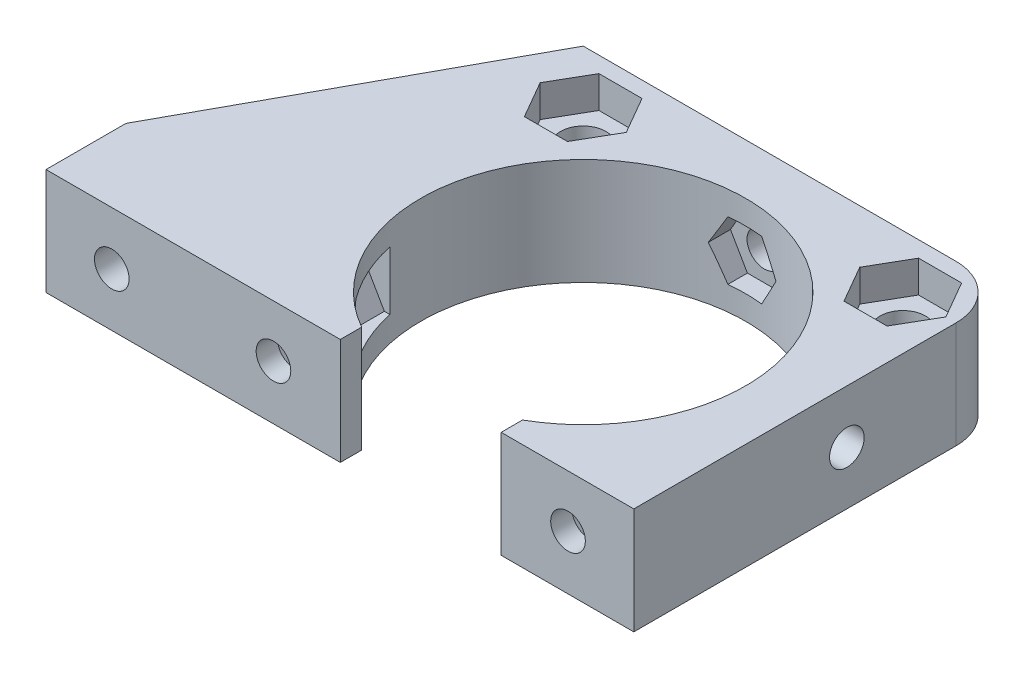
from build123d import *

# Parameters (mm, degrees)
CROQUIS1_R                              = 15.25
CROQUIS1_R_2                            = 2.125
SOPORTE_CAJA_REDUCTORA_DEPTH            = 20
CROQUIS3_R                              = 2.125
CORTAR_EXTRUIR1_DEPTH                   = 51.423828692
REDONDEO1_R                             = 5
BOSS_EXTRUDE1_DEPTH                     = 20
CUT_EXTRUDE1_REACH                      = 55.852
SKETCH2_R                               = 1.625
CUT_EXTRUDE2_DEPTH                      = 2
SKETCH4_R                               = 1.625
CUT_EXTRUDE3_DEPTH                      = 63.291652731
CUT_EXTRUDE4_START                      = -4.5
CUT_EXTRUDE4_DEPTH                      = 2
CROQUIS6_W                              = 4.75
CROQUIS6_H                              = 4.75
CORTAR_EXTRUIR17_DEPTH                  = 42.231056256
CROQUIS7_W                              = 60
CROQUIS7_H                              = 20
CORTAR_EXTRUIR18_DEPTH                  = 51.423828692
SALIENTE_EXTRUIR2_DEPTH                 = 49
SOPORTE_START                           = -15
SOPORTE_MOTOR_DEPTH                     = 15
CROQUIS12_R                             = 2.125
AGUJEROS_DE_SUJECION_A_BASE_DEPTH       = 84.087679592
TUERCA_START                            = -4
TUERCA_AGUJERO_DE_SUJECION_A_BASE_DEPTH = 10
SALIENTE_EXTRUIR4_DEPTH                 = 15
CORTAR_EXTRUIR19_DEPTH                  = 25
CROQUIS14_W                             = 50
CROQUIS14_H                             = 118
CORTAR_EXTRUIR22_DEPTH                  = 146.556045907
CROQUIS15_W                             = 10
CROQUIS15_H                             = 7
CORTAR_EXTRUIR23_DEPTH                  = 42.231056256
CORTAR_EXTRUIR24_DEPTH                  = 42.231056256
CROQUIS18_W                             = 40
CROQUIS18_H                             = 10
CORTAR_EXTRUIR25_DEPTH                  = 44.27311521
SALIENTE_EXTRUIR5_DEPTH                 = 10
CROQUIS20_R                             = 1
CORTAR_EXTRUIR26_DEPTH                  = 49.229270158
CORTAR_EXTRUIR27_REACH                  = 62.959
CORTAR_EXTRUIR27_END_RADIUS             = 15.25
CROQUIS21_R                             = 1.625
CROQUIS22_R                             = 2.125
CROQUIS22_R_2                           = 1
SALIENTE_EXTRUIR6_DEPTH                 = 10
CROQUIS23_R                             = 1.625
CORTAR_EXTRUIR28_DEPTH                  = 52.269508521
CORTAR_EXTRUIR29_START                  = -3
CORTAR_EXTRUIR29_DEPTH                  = 10
SALIENTE_EXTRUIR7_DEPTH                 = 10
CORTAR_EXTRUIR30_REACH                  = 72.235
CROQUIS27_R                             = 1.625
CORTAR_EXTRUIR31_REACH                  = 75.235
CORTAR_EXTRUIR31_START                  = -3
CORTAR_EXTRUIR32_REACH                  = 58.612
CROQUIS29_R                             = 1.625
CORTAR_EXTRUIR33_REACH                  = 61.112
CORTAR_EXTRUIR33_START                  = -2.5
CROQUIS35_W                             = 13.305418987
CROQUIS35_H                             = 6.826864192
CORTAR_EXTRUIR34_DEPTH                  = 63.931555098
CORTAR_EXTRUIR34_DEPTH_BACK             = 63.931555098
CORTAR_EXTRUIR35_START                  = -3
CORTAR_EXTRUIR35_DEPTH                  = 10
SALIENTE_EXTRUIR8_DEPTH                 = 10
SALIENTE_EXTRUIR9_DEPTH                 = 13
SALIENTE_EXTRUIR10_DEPTH                = 3
CROQUIS40_W                             = 106.583537839
CROQUIS40_H                             = 47.391515964
CORTAR_EXTRUIR36_DEPTH                  = 80.887064817
CORTAR_EXTRUIR36_DEPTH_BACK             = 80.887064817
CORTAR_EXTRUIR37_DEPTH                  = 67.2524009
CORTAR_EXTRUIR37_DEPTH_BACK             = 67.2524009
CORTAR_EXTRUIR38_DEPTH                  = 79.704784639
CORTAR_EXTRUIR38_DEPTH_BACK             = 79.704784639
SALIENTE_EXTRUIR11_DEPTH                = 10
CORTAR_EXTRUIR39_DEPTH                  = 63.9908649
CROQUIS45_W                             = 31.470301378
CROQUIS45_H                             = 10
CROQUIS45_R                             = 1.625
SALIENTE_EXTRUIR12_DEPTH                = 2.5
SALIENTE_EXTRUIR13_DEPTH                = 10
CORTAR_EXTRUIR40_START                  = -2
CROQUIS47_R                             = 1.625
CORTAR_EXTRUIR40_DEPTH                  = 10
CORTAR_EXTRUIR41_START                  = -12
CROQUIS48_R                             = 1.625
CORTAR_EXTRUIR41_DEPTH                  = 12
CORTAR_EXTRUIR42_DEPTH                  = 3
CROQUIS50_R                             = 2.125
CORTAR_EXTRUIR43_DEPTH                  = 52.795622989
CORTAR_EXTRUIR43_DEPTH_BACK             = 52.795622989
CORTAR_EXTRUIR44_DEPTH                  = 52.795622989
CORTAR_EXTRUIR44_DEPTH_BACK             = 52.795622989
SALIENTE_EXTRUIR14_DEPTH                = 10
CORTAR_EXTRUIR45_START                  = -24.591895
CORTAR_EXTRUIR45_DEPTH                  = 17.091895


with BuildPart() as part:
    # Croquis1 → Soporte caja reductora (new body)
    with BuildSketch(Plane(origin=(0, 0, 0), x_dir=(1, 0, 0), z_dir=(0, 1, 0))):
        Polygon((-30, -15.25), (-20, -15.25), (-20, -20), (20, -20), (20, -15.25), (30, -15.25), (30, -7.25), (20, -4.25), (20, 20), (-20, 20), (-20, -4.25), (-30, -7.25), align=None)
        with Locations(Location((0, 0, 0), (0, 0, 270))):
            Circle(CROQUIS1_R, mode=Mode.SUBTRACT)
        with Locations(Location((-15, 15, 0), (0, 0, 270))):
            Circle(CROQUIS1_R_2, mode=Mode.SUBTRACT)
        with Locations(Location((15, 15, 0), (0, 0, 270))):
            Circle(CROQUIS1_R_2, mode=Mode.SUBTRACT)
    extrude(amount=-SOPORTE_CAJA_REDUCTORA_DEPTH)

    # Croquis3 → Cortar-Extruir1 (cut, through all)
    with BuildSketch(Plane.XY.offset(15.25)):
        with Locations((-23.5, -10)):
            Circle(CROQUIS3_R)
        with Locations((23.5, -10)):
            Circle(CROQUIS3_R)
    extrude(amount=-CORTAR_EXTRUIR1_DEPTH, mode=Mode.SUBTRACT)

    # Redondeo1
    redondeo1_edges = [part.edges().sort_by_distance(p)[0] for p in [
        (-20, -10, -20),
        (20, -10, -20),
    ]]
    fillet(redondeo1_edges, radius=REDONDEO1_R)

    # Sketch1 → Boss-Extrude1 (add)
    with BuildSketch(Plane(origin=(0, 0, 0), x_dir=(1, 0, 0), z_dir=(0, 1, 0))):
        with BuildLine():
            Line((25.5, 15), (20, 15))
            ThreePointArc((20, 15), (18.535533906, 18.535533906), (15, 20))
            Line((15, 20), (30, 20))
            Line((30, 20), (30, 8))
            Line((30, 8), (25.5, 8))
            Line((25.5, 8), (25.5, 15))
        make_face()
    extrude(amount=-BOSS_EXTRUDE1_DEPTH)

    # Sketch2 → Cut-Extrude1 (cut, up to next)
    with BuildSketch(Plane(origin=(0, 0, -20), x_dir=(-1, 0, 0), z_dir=(0, 0, -1)), mode=Mode.PRIVATE) as cut_extrude1_sk1:
        with Locations((-22.75, -10)):
            Circle(SKETCH2_R)
    cut_extrude1_tool1 = extrude(cut_extrude1_sk1.sketch, amount=-CUT_EXTRUDE1_REACH, mode=Mode.PRIVATE) & part.part
    add(cut_extrude1_tool1.solids().sort_by_distance((22.75, -10, -20))[0], mode=Mode.SUBTRACT)

    # Sketch3 → Cut-Extrude2 (cut)
    with BuildSketch(Plane.XY.offset(-15)):
        Polygon((20, -11.58771324), (22.75, -13.175426481), (25.5, -11.58771324), (25.5, -8.41228676), (22.75, -6.824573519), (20, -8.41228676), align=None)
    extrude(amount=-CUT_EXTRUDE2_DEPTH, mode=Mode.SUBTRACT)

    # Sketch4 → Cut-Extrude3 (cut, through all)
    with BuildSketch(Plane.ZY.offset(-25.5)):
        with Locations((-12.25, -10)):
            Circle(SKETCH4_R)
    extrude(amount=-CUT_EXTRUDE3_DEPTH, mode=Mode.SUBTRACT)

    # Sketch5 → Cut-Extrude4 (cut)
    with BuildSketch(Plane(origin=(30, 0, 0), x_dir=(0, 0, -1), z_dir=(1, 0, 0)).offset(CUT_EXTRUDE4_START)):
        Polygon((15, -11.58771324), (15, -8.41228676), (12.25, -6.824573519), (9.5, -8.41228676), (9.5, -11.58771324), (12.25, -13.175426481), align=None)
    extrude(amount=CUT_EXTRUDE4_DEPTH, mode=Mode.SUBTRACT)

    # Croquis6 → Cortar-Extruir17 (cut, through all)
    with BuildSketch(Plane(origin=(0, 0, 0), x_dir=(1, 0, 0), z_dir=(0, 1, 0))):
        Polygon((0, -15.25), (-15.25, -15.25), (-15.25, -20), (15.25, -20), (15.25, -15.25), align=None)
        with Locations((-17.625, -17.625)):
            Rectangle(CROQUIS6_W, CROQUIS6_H)
        with BuildLine():
            ThreePointArc((0, -15.25), (-10.783378413, -10.783378413), (-15.25, 0))
            Line((-15.25, 0), (-15.25, -15.25))
            Line((-15.25, -15.25), (0, -15.25))
        make_face()
        with BuildLine():
            Line((15.25, -15.25), (15.25, 0))
            ThreePointArc((15.25, 0), (10.783378413, -10.783378413), (0, -15.25))
            Line((0, -15.25), (15.25, -15.25))
        make_face()
        with Locations((17.625, -17.625)):
            Rectangle(CROQUIS6_W, CROQUIS6_H)
    extrude(amount=-CORTAR_EXTRUIR17_DEPTH, mode=Mode.SUBTRACT)


with BuildPart() as body_2:
    # Simetría1: mirrored copy
    add(part.part.mirror(Plane.ZX))

    # Croquis8 → Saliente-Extruir2 (add)
    with BuildSketch(Plane(origin=(0, 20, 0), x_dir=(1, 0, 0), z_dir=(0, 1, 0))):
        with BuildLine():
            Line((-12.664515522, 20), (-11.040489496, 13.939052358))
            Line((-11.040489496, 13.939052358), (-10.315162126, 11.232093763))
            ThreePointArc((-10.315162126, 11.232093763), (0, 15.25), (10.315162126, 11.232093763))
            Line((10.315162126, 11.232093763), (10.817418481, 13.87928066))
            Line((10.817418481, 13.87928066), (11.978715476, 20))
            Line((11.978715476, 20), (-12.664515522, 20))
        make_face()
    extrude(amount=SALIENTE_EXTRUIR2_DEPTH)

    # Croquis9 → Soporte motor (add)
    with BuildSketch(Plane(origin=(0, 69, 0), x_dir=(1, 0, 0), z_dir=(0, 1, 0)).offset(SOPORTE_START)):
        with BuildLine():
            Line((-20, 15), (-20, -4.25))
            Line((-20, -4.25), (-30, -7.25))
            Line((-30, -7.25), (-30, -15.25))
            Line((-30, -15.25), (0, -15.25))
            Line((0, -15.25), (0, -14.75))
            ThreePointArc((0, -14.75), (-10.429825023, 10.429825023), (14.75, 0))
            Line((14.75, 0), (20, 0))
            Line((20, 0), (20, 13.936837101))
            Line((20, 13.936837101), (12.664515522, 20))
            Line((12.664515522, 20), (-15, 20))
            ThreePointArc((-15, 20), (-18.535533906, 18.535533906), (-20, 15))
        make_face()
    extrude(amount=-SOPORTE_MOTOR_DEPTH)

    # Croquis12 → Agujeros de sujecion a base (cut, through all)
    with BuildSketch(Plane.XY.offset(15.25)):
        with Locations((-23.5, 46.5)):
            Circle(CROQUIS12_R)
    extrude(amount=-AGUJEROS_DE_SUJECION_A_BASE_DEPTH, mode=Mode.SUBTRACT)

    # Croquis13 → Tuerca Agujero de sujecion a base (cut)
    with BuildSketch(Plane.XY.offset(15.25).offset(TUERCA_START)):
        Polygon((-20, 44.479274058), (-20, 48.520725942), (-23.5, 50.541451884), (-27, 48.520725942), (-27, 44.479274058), (-23.5, 42.458548116), align=None)
    extrude(amount=-TUERCA_AGUJERO_DE_SUJECION_A_BASE_DEPTH, mode=Mode.SUBTRACT)

    # Croquis10 → Saliente-Extruir4 (add)
    with BuildSketch(Plane(origin=(0, 69, 0), x_dir=(1, 0, 0), z_dir=(0, 1, 0))):
        with BuildLine():
            ThreePointArc((10.315162126, 11.232093763), (0, 15.25), (-10.315162126, 11.232093763))
            Line((-10.315162126, 11.232093763), (-10.16850369, 10.684757026))
            ThreePointArc((-10.16850369, 10.684757026), (0, 14.75), (10.16850369, 10.684757026))
            Line((10.16850369, 10.684757026), (10.315162126, 11.232093763))
        make_face()
    extrude(amount=-SALIENTE_EXTRUIR4_DEPTH)

    # Croquis11 → Cortar-Extruir19 (cut)
    with BuildSketch(Plane.XZ):
        with BuildLine():
            Line((15.25, 4.25), (20, 4.25))
            Line((20, 4.25), (21.972856468, 4.84185694))
            ThreePointArc((21.972856468, 4.84185694), (19.948931102, 10.40625523), (16.543503257, 15.25))
            Line((16.543503257, 15.25), (15.25, 15.25))
            Line((15.25, 15.25), (15.25, 4.25))
        make_face()
        with BuildLine():
            Line((21.972856468, 4.84185694), (30, 7.25))
            Line((30, 7.25), (30, 15.25))
            Line((30, 15.25), (16.543503257, 15.25))
            ThreePointArc((16.543503257, 15.25), (19.948931102, 10.40625523), (21.972856468, 4.84185694))
        make_face()
        with BuildLine():
            ThreePointArc((20, -15), (18.535533906, -18.535533906), (15, -20))
            Line((15, -20), (30, -20))
            Line((30, -20), (30, -8))
            Line((30, -8), (25.5, -8))
            Line((25.5, -8), (25.5, -15))
            Line((25.5, -15), (20, -15))
        make_face()
    extrude(amount=-CORTAR_EXTRUIR19_DEPTH, mode=Mode.SUBTRACT)

    # Simetría2: body 2 across face


with BuildPart() as part_1:
    add(part.part)

    # Croquis7 → Cortar-Extruir18 (cut, through all)
    with BuildSketch(Plane(origin=(0, 0, -20), x_dir=(-1, 0, 0), z_dir=(0, 0, -1))):
        with Locations((0, -10)):
            Rectangle(CROQUIS7_W, CROQUIS7_H)
    extrude(amount=-CORTAR_EXTRUIR18_DEPTH, mode=Mode.SUBTRACT)


with BuildPart() as body_2_1:
    add(body_2.part)
    add(body_2.part.mirror(Plane(origin=(-0.229209569, 69, -16.663998028), x_dir=(0, 0, 1), z_dir=(0, 1, 0))))

    # Croquis14 → Cortar-Extruir22 (cut, through all)
    with BuildSketch(Plane.XY.offset(15.25)):
        with Locations((-5, 79)):
            Rectangle(CROQUIS14_W, CROQUIS14_H)
    extrude(amount=-CORTAR_EXTRUIR22_DEPTH, mode=Mode.SUBTRACT)

    # Croquis15 → Cortar-Extruir23 (cut, through all)
    with BuildSketch(Plane.XZ):
        with Locations((-25, 7.75)):
            Rectangle(CROQUIS15_W, CROQUIS15_H)
    extrude(amount=-CORTAR_EXTRUIR23_DEPTH, mode=Mode.SUBTRACT)

    # Croquis16 → Cortar-Extruir24 (cut, through all)
    with BuildSketch(Plane.XZ):
        Polygon((-30, 15.25), (-15.25, 15.25), (-15.25, 12.75), (-20, 12.75), (-20, 11.25), (-30, 11.25), (-30, 12.75), align=None)
    extrude(amount=-CORTAR_EXTRUIR24_DEPTH, mode=Mode.SUBTRACT)

    # Croquis18 → Cortar-Extruir25 (cut, through all)
    with BuildSketch(Plane(origin=(0, 0, -20), x_dir=(-1, 0, 0), z_dir=(0, 0, -1))):
        with Locations((0, 5)):
            Rectangle(CROQUIS18_W, CROQUIS18_H)
    extrude(amount=-CORTAR_EXTRUIR25_DEPTH, mode=Mode.SUBTRACT)

    # Croquis19 → Saliente-Extruir5 (add)
    with BuildSketch(Plane(origin=(0, 20, 0), x_dir=(1, 0, 0), z_dir=(0, 1, 0))):
        Polygon((-20, -12.75), (-34, -12.75), (-34, -7.75), (-24, -7.75), (-20, -3.75), align=None)
    extrude(amount=-SALIENTE_EXTRUIR5_DEPTH)

    # Croquis20 → Cortar-Extruir26 (cut, through all)
    with BuildSketch(Plane(origin=(0, 0, 7.75), x_dir=(-1, 0, 0), z_dir=(0, 0, -1))):
        with Locations((29, 15)):
            Circle(CROQUIS20_R)
    extrude(amount=-CORTAR_EXTRUIR26_DEPTH, mode=Mode.SUBTRACT)

    # Cortar-Extruir27: up to this cylinder (the profile starts outside it)
    cortar_extruir27_end = Plane(origin=(0, 15, 0), z_dir=(0, -1, 0)) * Cylinder(CORTAR_EXTRUIR27_END_RADIUS, 157.418, mode=Mode.PRIVATE)
    # Croquis21 → Cortar-Extruir27 (cut, up to the surface)
    with BuildSketch(Plane(origin=(20, 0, 0), x_dir=(0, 0, -1), z_dir=(1, 0, 0)), mode=Mode.PRIVATE) as cortar_extruir27_sk1:
        with Locations((4.75, 15)):
            Circle(CROQUIS21_R)
    cortar_extruir27_tool1 = extrude(cortar_extruir27_sk1.sketch, amount=-CORTAR_EXTRUIR27_REACH, mode=Mode.PRIVATE) - cortar_extruir27_end
    add(cortar_extruir27_tool1.solids().sort_by_distance((20, 15, -4.75))[0], mode=Mode.SUBTRACT)

    # Croquis22 → Saliente-Extruir6 (add)
    with BuildSketch(Plane.XZ.offset(-10)):
        with Locations((-15, -15)):
            Circle(CROQUIS22_R)
        with Locations(Location((-15, -15, 0), (0, 0, 270))):
            Circle(CROQUIS22_R_2, mode=Mode.SUBTRACT)
        with Locations((15, -15)):
            Circle(CROQUIS22_R)
        with Locations(Location((15, -15, 0), (0, 0, 270))):
            Circle(CROQUIS22_R_2, mode=Mode.SUBTRACT)
    extrude(amount=-SALIENTE_EXTRUIR6_DEPTH)

    # Croquis23 → Cortar-Extruir28 (cut, through all)
    with BuildSketch(Plane(origin=(0, 0, -20), x_dir=(-1, 0, 0), z_dir=(0, 0, -1))):
        with Locations((0, 15)):
            Circle(CROQUIS23_R)
    extrude(amount=-CORTAR_EXTRUIR28_DEPTH, mode=Mode.SUBTRACT)

    # Croquis24 → Cortar-Extruir29 (cut)
    with BuildSketch(Plane(origin=(0, 0, -20), x_dir=(-1, 0, 0), z_dir=(0, 0, -1)).offset(CORTAR_EXTRUIR29_START)):
        Polygon((1.58771324, 12.25), (3.175426481, 15), (1.58771324, 17.75), (-1.58771324, 17.75), (-3.175426481, 15), (-1.58771324, 12.25), align=None)
    extrude(amount=-CORTAR_EXTRUIR29_DEPTH, mode=Mode.SUBTRACT)

    # Croquis26 → Saliente-Extruir7 (add)
    with BuildSketch(Plane.XZ.offset(-10)):
        Polygon((-34, 7.75), (-34, 12.75), (-58.825, 12.75), (-39.160527763, -4.104491148), (-20, -4.104491148), (-20, -0.104491148), (-35.732113118, -0.104491148), (-29, 7.75), align=None)
        Polygon((-34.268209086, 7.75), (-39.594516123, 1.535690951), (-46.844874897, 7.75), align=None, mode=Mode.SUBTRACT)
    extrude(amount=-SALIENTE_EXTRUIR7_DEPTH)

    # Croquis27 → Cortar-Extruir30 (cut, up to next)
    with BuildSketch(Plane.XY.offset(12.75), mode=Mode.PRIVATE) as cortar_extruir30_sk1:
        with Locations((-40.544874897, 15)):
            Circle(CROQUIS27_R)
    cortar_extruir30_tool1 = extrude(cortar_extruir30_sk1.sketch, amount=-CORTAR_EXTRUIR30_REACH, mode=Mode.PRIVATE) & body_2_1.part
    # Croquis27 → Cortar-Extruir30 (cut, up to next)
    with BuildSketch(Plane.XY.offset(12.75), mode=Mode.PRIVATE) as cortar_extruir30_sk2:
        with Locations((-29, 15)):
            Circle(CROQUIS27_R)
    cortar_extruir30_tool2 = extrude(cortar_extruir30_sk2.sketch, amount=-CORTAR_EXTRUIR30_REACH, mode=Mode.PRIVATE) & body_2_1.part
    add(cortar_extruir30_tool1.solids().sort_by_distance((-40.544875, 15, 12.75))[0], mode=Mode.SUBTRACT)
    add(cortar_extruir30_tool2.solids().sort_by_distance((-29, 15, 12.75))[0], mode=Mode.SUBTRACT)

    # Croquis28 → Cortar-Extruir31 (cut, up to next)
    with BuildSketch(Plane.XY.offset(12.75).offset(CORTAR_EXTRUIR31_START), mode=Mode.PRIVATE) as cortar_extruir31_sk1:
        Polygon((-38.957161657, 12.25), (-37.369448416, 15), (-38.957161657, 17.75), (-42.132588137, 17.75), (-43.720301378, 15), (-42.132588137, 12.25), align=None)
    cortar_extruir31_tool1 = extrude(cortar_extruir31_sk1.sketch, amount=-CORTAR_EXTRUIR31_REACH, mode=Mode.PRIVATE) & body_2_1.part
    # Croquis28 → Cortar-Extruir31 (cut, up to next)
    with BuildSketch(Plane.XY.offset(12.75).offset(CORTAR_EXTRUIR31_START), mode=Mode.PRIVATE) as cortar_extruir31_sk2:
        Polygon((-27.41228676, 12.25), (-25.824573519, 15), (-27.41228676, 17.75), (-30.58771324, 17.75), (-32.175426481, 15), (-30.58771324, 12.25), align=None)
    cortar_extruir31_tool2 = extrude(cortar_extruir31_sk2.sketch, amount=-CORTAR_EXTRUIR31_REACH, mode=Mode.PRIVATE) & body_2_1.part
    add(cortar_extruir31_tool1.solids().sort_by_distance((-40.544875, 15, 9.75))[0], mode=Mode.SUBTRACT)
    add(cortar_extruir31_tool2.solids().sort_by_distance((-29, 15, 9.75))[0], mode=Mode.SUBTRACT)

    # Croquis29 → Cortar-Extruir32 (cut, up to next)
    with BuildSketch(Plane(origin=(-18.612848159, 0, -21.715982563), x_dir=(-0.7592713073348843, 0, 0.6507742172658468), z_dir=(-0.6507742172658468, 0, -0.7592713073348843)), mode=Mode.PRIVATE) as cortar_extruir32_sk1:
        with Locations((33.812368097, 15)):
            Circle(CROQUIS29_R)
    cortar_extruir32_tool1 = extrude(cortar_extruir32_sk1.sketch, amount=-CORTAR_EXTRUIR32_REACH, mode=Mode.PRIVATE) & body_2_1.part
    add(cortar_extruir32_tool1.solids().sort_by_distance((-44.285609, 15, 0.288235))[0], mode=Mode.SUBTRACT)

    # Croquis31 → Cortar-Extruir33 (cut, up to next)
    with BuildSketch(Plane(origin=(-18.612848159, 0, -21.715982563), x_dir=(-0.7592713073348843, 0, 0.6507742172658468), z_dir=(-0.6507742172658468, 0, -0.7592713073348843)).offset(CORTAR_EXTRUIR33_START), mode=Mode.PRIVATE) as cortar_extruir33_sk1:
        Polygon((36.562368097, 16.58771324), (33.812368097, 18.175426481), (31.062368097, 16.58771324), (31.062368097, 13.41228676), (33.812368097, 11.824573519), (36.562368097, 13.41228676), align=None)
    cortar_extruir33_tool1 = extrude(cortar_extruir33_sk1.sketch, amount=-CORTAR_EXTRUIR33_REACH, mode=Mode.PRIVATE) & body_2_1.part
    add(cortar_extruir33_tool1.solids().sort_by_distance((-42.658674, 15, 2.186413))[0], mode=Mode.SUBTRACT)

    # Croquis35 → Cortar-Extruir34 (cut, two sides)
    with BuildSketch(Plane(origin=(0, 20, 0), x_dir=(1, 0, 0), z_dir=(0, 1, 0))) as cortar_extruir34_sk:
        with Locations((17.04227466, -3.413432096)):
            Rectangle(CROQUIS35_W, CROQUIS35_H)
    extrude(amount=CORTAR_EXTRUIR34_DEPTH, mode=Mode.SUBTRACT)
    extrude(cortar_extruir34_sk.sketch, amount=-CORTAR_EXTRUIR34_DEPTH_BACK, mode=Mode.SUBTRACT)

    # Croquis36 → Cortar-Extruir35 (cut)
    with BuildSketch(Plane(origin=(20, 0, 0), x_dir=(0, 0, -1), z_dir=(1, 0, 0)).offset(CORTAR_EXTRUIR35_START)):
        Polygon((7.5, 16.58771324), (4.75, 18.175426481), (2, 16.58771324), (2, 13.41228676), (4.75, 11.824573519), (7.5, 13.41228676), align=None)
    extrude(amount=-CORTAR_EXTRUIR35_DEPTH, mode=Mode.SUBTRACT)

    # Croquis37 → Saliente-Extruir8 (add)
    with BuildSketch(Plane.XZ.offset(-10)):
        Polygon((-39.160527763, -4.104491148), (-20.614919368, -20), (-15, -20), (-19.558128305, -15.637570403), (-33.014002756, -4.104491148), align=None)
    extrude(amount=-SALIENTE_EXTRUIR8_DEPTH)

    # Croquis38 → Saliente-Extruir9 (add)
    with BuildSketch(Plane.XZ.offset(-10)):
        Polygon((-58.825, 12.75), (-38.825, 12.75), (-38.825, 9.75), (-55.324839942, 9.75), align=None)
    extrude(amount=SALIENTE_EXTRUIR9_DEPTH)

    # Croquis39 → Saliente-Extruir10 (add)
    with BuildSketch(Plane.XZ.offset(-10)):
        Polygon((-38.825, 9.75), (-38.825, 7.75), (-38.825, 5.75), (-50.657959865, 5.75), (-52.991399903, 7.75), (-55.324839942, 9.75), align=None)
    extrude(amount=SALIENTE_EXTRUIR10_DEPTH)

    # Simetría3: body 2 across face


with BuildPart() as body_2_2:
    add(body_2_1.part)
    add(body_2_1.part.mirror(Plane(origin=(-18.003999227, 20, -4.220503046), x_dir=(0, 0, 1), z_dir=(0, 1, 0))))

    # Croquis40 → Cortar-Extruir36 (cut, two sides)
    with BuildSketch(Plane(origin=(0, 0, -20), x_dir=(-1, 0, 0), z_dir=(0, 0, -1))) as cortar_extruir36_sk:
        with Locations((22.395502026, -3.695757982)):
            Rectangle(CROQUIS40_W, CROQUIS40_H)
    extrude(amount=CORTAR_EXTRUIR36_DEPTH, mode=Mode.SUBTRACT)
    extrude(cortar_extruir36_sk.sketch, amount=-CORTAR_EXTRUIR36_DEPTH_BACK, mode=Mode.SUBTRACT)

    # Croquis41 → Cortar-Extruir37 (cut, two sides)
    with BuildSketch(Plane.XZ.offset(-20)) as cortar_extruir37_sk:
        Polygon((-19.992980133, -22.302484261), (-20, 3.75), (-24, 7.75), (-56.035110209, 7.75), align=None)
    extrude(amount=CORTAR_EXTRUIR37_DEPTH, mode=Mode.SUBTRACT)
    extrude(cortar_extruir37_sk.sketch, amount=-CORTAR_EXTRUIR37_DEPTH_BACK, mode=Mode.SUBTRACT)

    # Croquis42 → Cortar-Extruir38 (cut, two sides)
    with BuildSketch(Plane(origin=(0, 0, 9.75), x_dir=(-1, 0, 0), z_dir=(0, 0, -1))) as cortar_extruir38_sk:
        Polygon((46.720301378, 20), (46.720301378, 30), (38.825, 30), (33.492952769, 43.760628779), (49.525340398, 48.951442806), (67.200390695, 42.512205152), (65.906601328, 20), (51.713995885, 13.864168239), align=None)
    extrude(amount=CORTAR_EXTRUIR38_DEPTH, mode=Mode.SUBTRACT)
    extrude(cortar_extruir38_sk.sketch, amount=-CORTAR_EXTRUIR38_DEPTH_BACK, mode=Mode.SUBTRACT)

    # Croquis43 → Saliente-Extruir11 (add)
    with BuildSketch(Plane.XZ.offset(-20)):
        Polygon((-19.993600539, -20), (-46.720301378, 7.75), (-43.839252857, 10.524807997), (-17.112552018, -17.225192003), align=None)
    extrude(amount=-SALIENTE_EXTRUIR11_DEPTH)

    # Croquis44 → Cortar-Extruir39 (cut, through all)
    with BuildSketch(Plane(origin=(0, 0, 9.75), x_dir=(-1, 0, 0), z_dir=(0, 0, -1))):
        Polygon((38.957161657, 27.75), (37.369448416, 25), (38.957161657, 22.25), (42.132588137, 22.25), (43.720301378, 25), (42.132588137, 27.75), align=None)
    extrude(amount=CORTAR_EXTRUIR39_DEPTH, mode=Mode.SUBTRACT)

    # Croquis45 → Saliente-Extruir12 (add)
    with BuildSketch(Plane.XY.offset(12.75)):
        with Locations((-30.985150689, 25)):
            Rectangle(CROQUIS45_W, CROQUIS45_H)
        with Locations((-40.544874897, 25)):
            Circle(CROQUIS45_R, mode=Mode.SUBTRACT)
        with Locations((-29, 25)):
            Circle(CROQUIS45_R, mode=Mode.SUBTRACT)
    extrude(amount=SALIENTE_EXTRUIR12_DEPTH)

    # Croquis46 → Saliente-Extruir13 (add)
    with BuildSketch(Plane.XZ.offset(-20)):
        with BuildLine():
            Line((15.25, 0), (20, 0))
            Line((20, 0), (20, 15.25))
            Line((20, 15.25), (7.549834435, 15.25))
            Line((7.549834435, 15.25), (7.549834435, 13.25))
            ThreePointArc((7.549834435, 13.25), (13.185171124, 7.662490615), (15.25, 0))
        make_face()
        with BuildLine():
            Line((-15.25, 0), (-15.25, 15.25))
            Line((-15.25, 15.25), (-7.549834435, 15.25))
            Line((-7.549834435, 15.25), (-7.549834435, 13.25))
            ThreePointArc((-7.549834435, 13.25), (-13.185171124, 7.662490615), (-15.25, 0))
        make_face()
    extrude(amount=-SALIENTE_EXTRUIR13_DEPTH)

    # Croquis47 → Cortar-Extruir40 (cut)
    with BuildSketch(Plane.XY.offset(15.25).offset(CORTAR_EXTRUIR40_START)):
        Polygon((15.41228676, 22.352505966), (17, 25.102505966), (15.41228676, 27.852505966), (12.236860279, 27.852505966), (10.649147039, 25.102505966), (12.236860279, 22.352505966), align=None)
        with Locations((13.824573519, 25.102505966)):
            Circle(CROQUIS47_R, mode=Mode.SUBTRACT)
        Polygon((-12.236860279, 22.352505966), (-15.41228676, 22.352505966), (-17, 25.102505966), (-15.41228676, 27.852505966), (-12.236860279, 27.852505966), (-10.649147039, 25.102505966), align=None)
        with Locations(Location((-13.824573519, 25.102505966, 0), (0, 0, 131.421584744))):
            Circle(CROQUIS47_R, mode=Mode.SUBTRACT)
    extrude(amount=-CORTAR_EXTRUIR40_DEPTH, mode=Mode.SUBTRACT)

    # Croquis48 → Cortar-Extruir41 (cut)
    with BuildSketch(Plane.XY.offset(15.25).offset(CORTAR_EXTRUIR41_START)):
        with Locations((13.824573519, 25.102505966)):
            Circle(CROQUIS48_R)
        with Locations((-13.824573519, 25.102505966)):
            Circle(CROQUIS48_R)
    extrude(amount=CORTAR_EXTRUIR41_DEPTH, mode=Mode.SUBTRACT)

    # Croquis49 → Cortar-Extruir42 (cut)
    with BuildSketch(Plane(origin=(0, 30, 0), x_dir=(1, 0, 0), z_dir=(0, 1, 0))):
        Polygon((-12.979274058, 11.5), (-10.958548116, 15), (-12.979274058, 18.5), (-17.020725942, 18.5), (-19.041451884, 15), (-17.020725942, 11.5), align=None)
        Polygon((17.020725942, 11.5), (19.041451884, 15), (17.020725942, 18.5), (12.979274058, 18.5), (10.958548116, 15), (12.979274058, 11.5), align=None)
    extrude(amount=-CORTAR_EXTRUIR42_DEPTH, mode=Mode.SUBTRACT)

    # Croquis50 → Cortar-Extruir43 (cut, two sides)
    with BuildSketch(Plane(origin=(0, 30, 0), x_dir=(1, 0, 0), z_dir=(0, 1, 0))) as cortar_extruir43_sk:
        with Locations(Location((-15, 15, 0), (0, 0, 270))):
            Circle(CROQUIS50_R)
        with Locations(Location((15, 15, 0), (0, 0, 270))):
            Circle(CROQUIS50_R)
    extrude(amount=CORTAR_EXTRUIR43_DEPTH, mode=Mode.SUBTRACT)
    extrude(cortar_extruir43_sk.sketch, amount=-CORTAR_EXTRUIR43_DEPTH_BACK, mode=Mode.SUBTRACT)

    # Croquis51 → Cortar-Extruir44 (cut, two sides)
    with BuildSketch(Plane(origin=(0, 30, 0), x_dir=(1, 0, 0), z_dir=(0, 1, 0))) as cortar_extruir44_sk:
        Polygon((-35.175426481, -15.25), (-35.175426481, -7.75), (-19.995154673, 14.232221634), (-19.993600539, 20), (-53.730413568, 5.241110817), (-52.418444784, -16.738442517), align=None)
    extrude(amount=CORTAR_EXTRUIR44_DEPTH, mode=Mode.SUBTRACT)
    extrude(cortar_extruir44_sk.sketch, amount=-CORTAR_EXTRUIR44_DEPTH_BACK, mode=Mode.SUBTRACT)

    # Croquis52 → Saliente-Extruir14 (add)
    with BuildSketch(Plane(origin=(0, 30, 0), x_dir=(1, 0, 0), z_dir=(0, 1, 0))):
        Polygon((-35.175426481, -7.75), (-19.993600539, 20), (-20, -3.75), (-24, -7.75), align=None)
    extrude(amount=-SALIENTE_EXTRUIR14_DEPTH)

    # Croquis54 → Cortar-Extruir45 (cut)
    with BuildSketch(Plane.XY.offset(15.25).offset(CORTAR_EXTRUIR45_START)):
        Polygon((-25.824573519, 25), (-27.41228676, 27.75), (-30.58771324, 27.75), (-32.175426481, 25), (-30.58771324, 22.25), (-27.41228676, 22.25), align=None)
    extrude(amount=CORTAR_EXTRUIR45_DEPTH, mode=Mode.SUBTRACT)


solid = body_2_2.part
